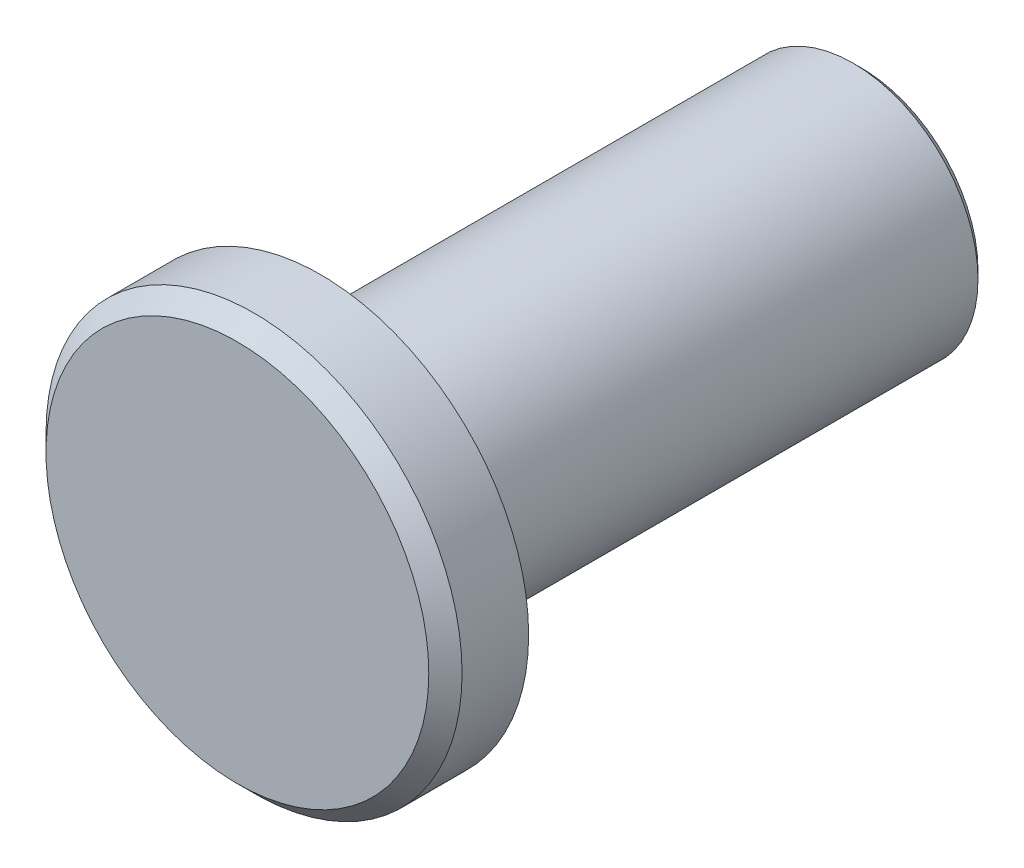
from build123d import *

# Parameters (mm, degrees)
SKETCH1_R           = 1.5
BOSS_EXTRUDE1_DEPTH = 6.5
CHAMFER1_SIZE       = 0.1
SKETCH2_R           = 2.5
BOSS_EXTRUDE2_DEPTH = 1
CHAMFER2_SIZE       = 0.2


with BuildPart() as part:
    # Sketch1 → Boss-Extrude1 (new body)
    with BuildSketch(Plane.XY):
        Circle(SKETCH1_R)
    extrude(amount=BOSS_EXTRUDE1_DEPTH)

    # Chamfer1
    chamfer1_edges = [part.edges().sort_by_distance(p)[0] for p in [
        (-1.5, 0, 0),
    ]]
    chamfer(chamfer1_edges, length=CHAMFER1_SIZE)

    # Sketch2 → Boss-Extrude2 (add)
    with BuildSketch(Plane.XY.offset(6.5)):
        Circle(SKETCH2_R)
    extrude(amount=BOSS_EXTRUDE2_DEPTH)

    # Chamfer2
    chamfer2_edges = [part.edges().sort_by_distance(p)[0] for p in [
        (-2.5, 0, 7.5),
    ]]
    chamfer(chamfer2_edges, length=CHAMFER2_SIZE)


solid = part.part
